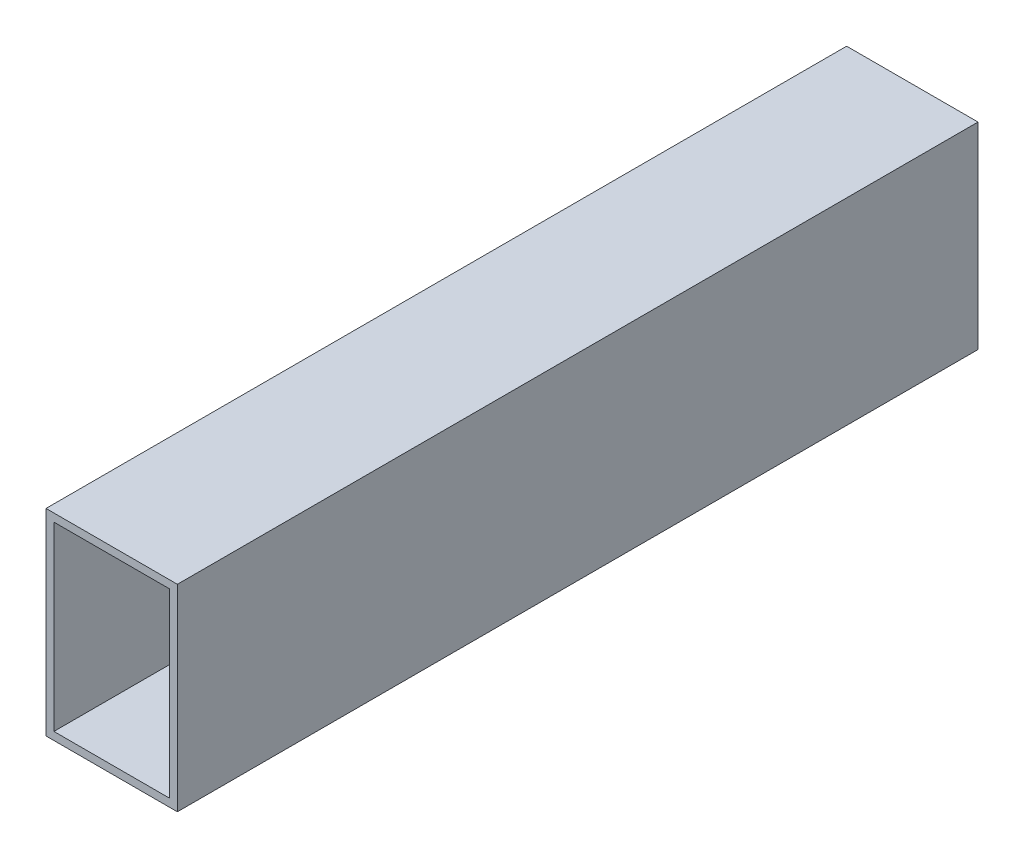
from build123d import *

# Parameters (mm, degrees)
SKETCH1_W           = 100
SKETCH1_H           = 150
SKETCH1_W_2         = 88
SKETCH1_H_2         = 138
BOSS_EXTRUDE1_DEPTH = 609.43814785


with BuildPart() as part:
    # Sketch1 → Boss-Extrude1 (new body)
    with BuildSketch(Plane.XY):
        Rectangle(SKETCH1_W, SKETCH1_H)
        Rectangle(SKETCH1_W_2, SKETCH1_H_2, mode=Mode.SUBTRACT)
    extrude(amount=BOSS_EXTRUDE1_DEPTH)


solid = part.part
